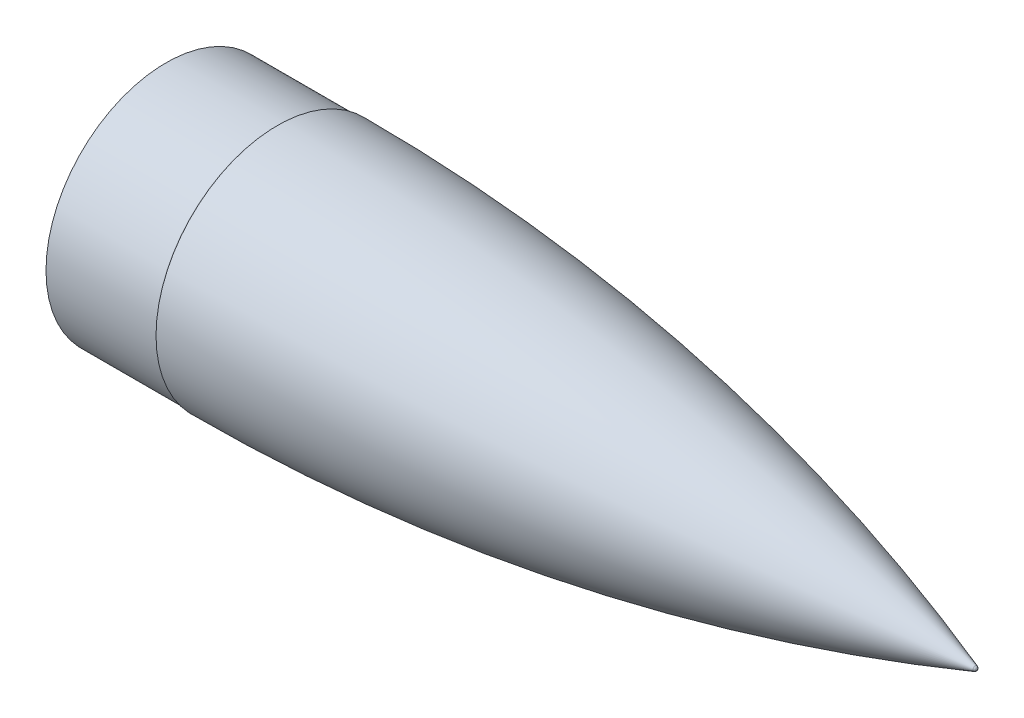
from build123d import *


with BuildPart() as part:
    # 草圖2 → 旋轉1 (revolve)
    with BuildSketch(Plane.XY):
        with BuildLine():
            Line((-558.8, 97), (-558.8, 96.88))
            ThreePointArc((-558.8, 96.88), (-559.092893219, 96.172893219), (-559.8, 95.88))
            Line((-559.8, 95.88), (-647.8, 95.88))
            Line((-647.8, 95.88), (-647.8, 93.88))
            Line((-647.8, 93.88), (-558.8, 93.88))
            Line((-558.8, 93.88), (-558.8, 93.499701976))
            ThreePointArc((-558.8, 93.499701976), (-558.506896015, 94.207019461), (-557.799403952, 94.499701798))
            ThreePointArc((-557.799403952, 94.499701798), (-276.669839321, 70.622370162), (-3.509739913, 0))
            Line((-3.509739913, 0), (0, 0))
            ThreePointArc((0, 0), (-0.368078983, 1.156215289), (-1.336833795, 1.88685203))
            ThreePointArc((-1.336833795, 1.88685203), (-276.040520675, 73.051137768), (-558.8, 97))
        make_face()
    revolve(axis=Axis((-711, 0, 0), (1, 0, 0)))


solid = part.part
